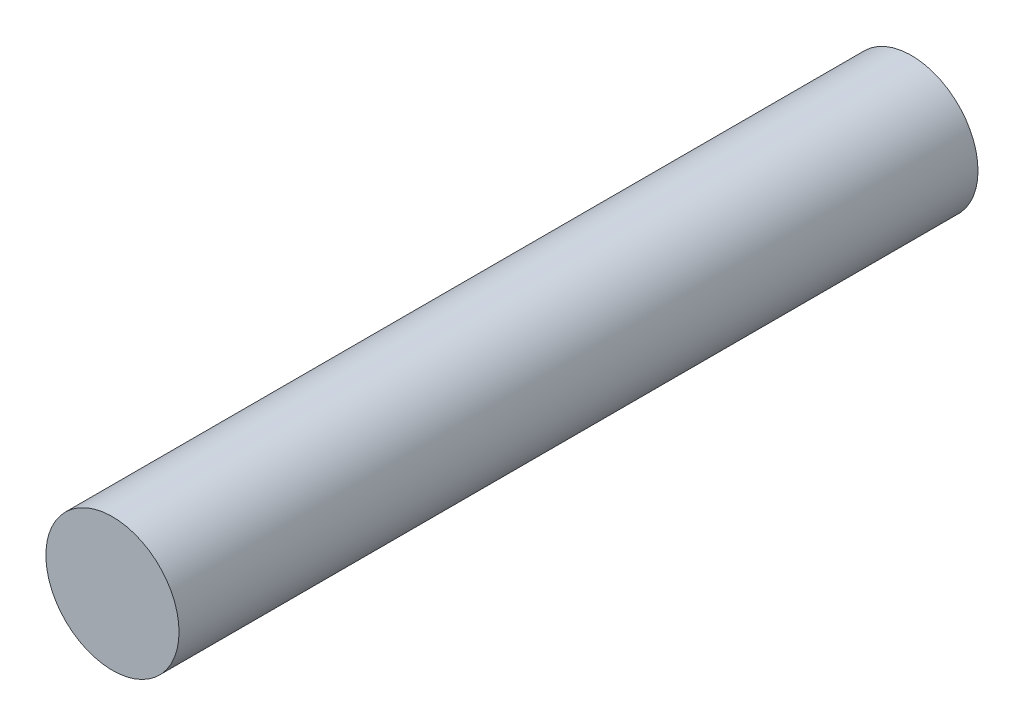
from build123d import *

# Parameters (mm, degrees)
SKETCH1_R           = 3.75
BOSS_EXTRUDE1_DEPTH = 45


with BuildPart() as part:
    # Sketch1 → Boss-Extrude1 (new body)
    with BuildSketch(Plane.XY):
        Circle(SKETCH1_R)
    extrude(amount=BOSS_EXTRUDE1_DEPTH)


solid = part.part
